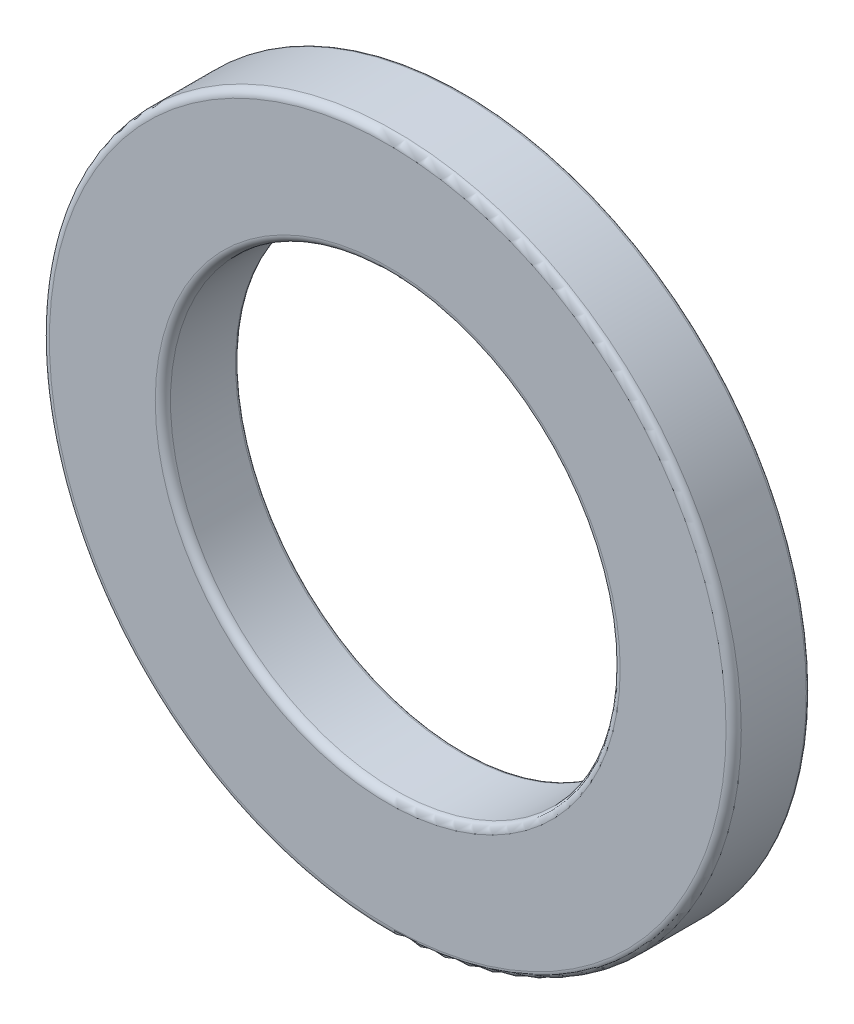
from build123d import *

# Parameters (mm, degrees)
SKETCH3_R                = 10
SKETCH3_R_2              = 6.5
BOSS_EXTRUDE1_DEPTH      = 1.1
BOSS_EXTRUDE1_DEPTH_BACK = 1.1
FILLET1_R                = 0.22
FILLET2_R                = 0.1


with BuildPart() as part:
    # Sketch3 → Boss-Extrude1 (new body, two sides)
    with BuildSketch(Plane.XY) as boss_extrude1_sk:
        Circle(SKETCH3_R)
        Circle(SKETCH3_R_2, mode=Mode.SUBTRACT)
    extrude(amount=BOSS_EXTRUDE1_DEPTH)
    extrude(boss_extrude1_sk.sketch, amount=-BOSS_EXTRUDE1_DEPTH_BACK)

    # Fillet1
    fillet1_edges = [part.edges().sort_by_distance(p)[0] for p in [
        (-10, 0, 1.1),
        (-6.5, 0, 1.1),
    ]]
    fillet(fillet1_edges, radius=FILLET1_R)

    # Fillet2
    fillet2_edges = [part.edges().sort_by_distance(p)[0] for p in [
        (-10, 0, -1.1),
        (-6.5, 0, -1.1),
    ]]
    fillet(fillet2_edges, radius=FILLET2_R)


solid = part.part
